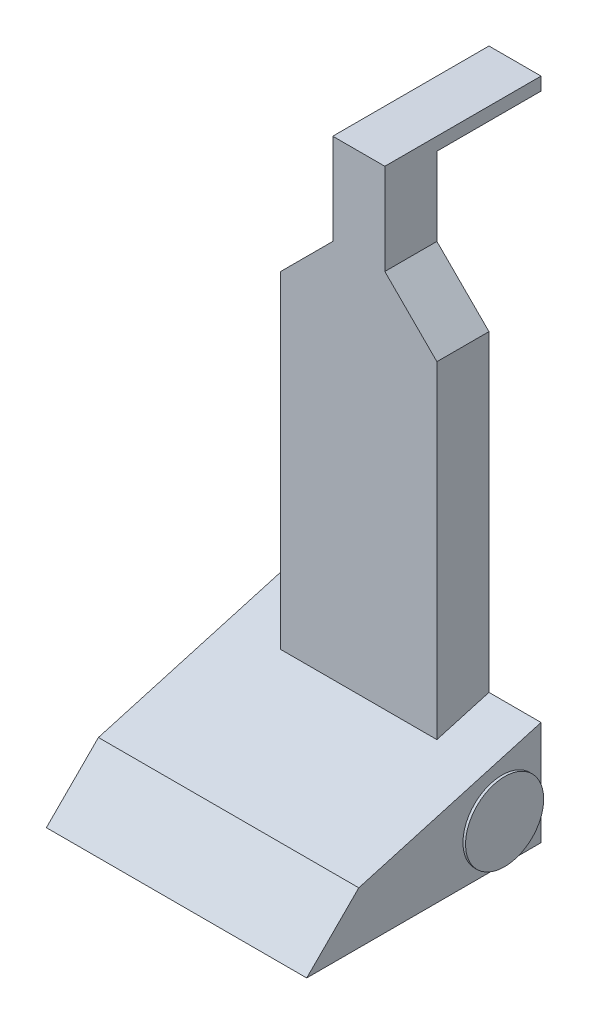
from build123d import *

# Parameters (mm, degrees)
EXTRUDE1_DEPTH = 50
SKETCH2_R      = 15
EXTRUDE2_DEPTH = 1
SKETCH3_R      = 15
EXTRUDE3_DEPTH = 1
SKETCH4_W      = 60
SKETCH4_H      = 20
EXTRUDE4_DEPTH = 180
CHAMFER1_SIZE  = 20
SKETCH5_W      = 20
SKETCH5_H      = 20
EXTRUDE5_DEPTH = 30
SKETCH6_W      = 20
SKETCH6_H      = 60
EXTRUDE6_DEPTH = 5


with BuildPart() as part:
    # Sketch1 → Extrude1 (new body, symmetric)
    with BuildSketch(Plane(origin=(0, 0, 0), x_dir=(0, 0, -1), z_dir=(1, 0, 0))):
        Polygon((0, 40), (0, 0), (-90, 0), (-70, 20), align=None)
    extrude(amount=EXTRUDE1_DEPTH, both=True)

    # Sketch4 → Extrude4 (add)
    with BuildSketch(Plane(origin=(0, 0, 0), x_dir=(1, 0, 0), z_dir=(0, 1, 0))):
        with Locations((0, -10)):
            Rectangle(SKETCH4_W, SKETCH4_H)
    extrude(amount=EXTRUDE4_DEPTH)

    # Chamfer1
    chamfer1_edges = [part.edges().sort_by_distance(p)[0] for p in [
        (-30, 180, 10),
        (30, 180, 10),
    ]]
    chamfer(chamfer1_edges, length=CHAMFER1_SIZE)

    # Sketch5 → Extrude5 (add)
    with BuildSketch(Plane(origin=(0, 180, 0), x_dir=(-1, 0, 0), z_dir=(0, 1, 0))):
        with Locations((0, 10)):
            Rectangle(SKETCH5_W, SKETCH5_H)
    extrude(amount=EXTRUDE5_DEPTH)

    # Sketch6 → Extrude6 (add)
    with BuildSketch(Plane(origin=(0, 210, 0), x_dir=(-1, 0, 0), z_dir=(0, 1, 0))):
        with Locations((0, -10)):
            Rectangle(SKETCH6_W, SKETCH6_H)
    extrude(amount=EXTRUDE6_DEPTH)


with BuildPart() as body_2:
    # Sketch2 → Extrude2 (new body)
    with BuildSketch(Plane(origin=(50, 0, 0), x_dir=(0, 0, -1), z_dir=(1, 0, 0))):
        with Locations((-15, 15)):
            Circle(SKETCH2_R)
    extrude(amount=EXTRUDE2_DEPTH)


with BuildPart() as body_3:
    # Sketch3 → Extrude3 (new body)
    with BuildSketch(Plane.ZY.offset(50)):
        with Locations((15, 15)):
            Circle(SKETCH3_R)
    extrude(amount=EXTRUDE3_DEPTH)


solid = Compound([part.part, body_2.part, body_3.part])
